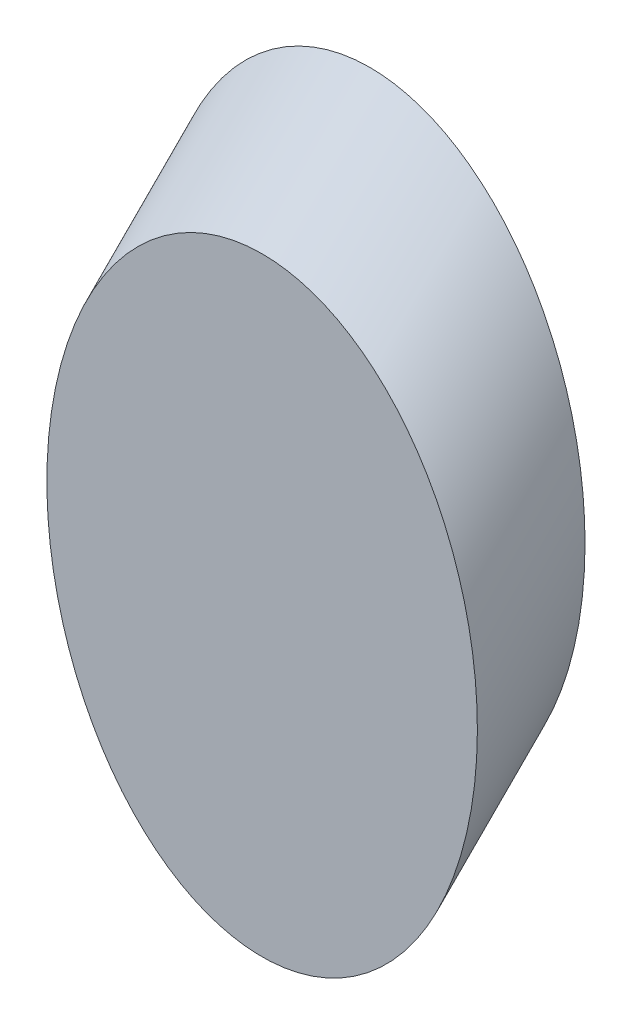
from build123d import *

# Parameters (mm, degrees)
SKETCH_1_RX     = 35.36
SKETCH_1_RY     = 25
EXTRUDE_2_DEPTH = 17.68


with BuildPart() as part:
    # 草图1 → 凸台-拉伸2 (new body, along a direction that is not the sketch's normal)
    with BuildSketch(Plane.XY):
        with Locations(Location((54.392382982, 35.78887153), (0, 0, 90))):
            Ellipse(SKETCH_1_RX, SKETCH_1_RY)
    extrude(amount=-EXTRUDE_2_DEPTH, dir=(0, -0.707106781, 0.707106781))


solid = part.part
